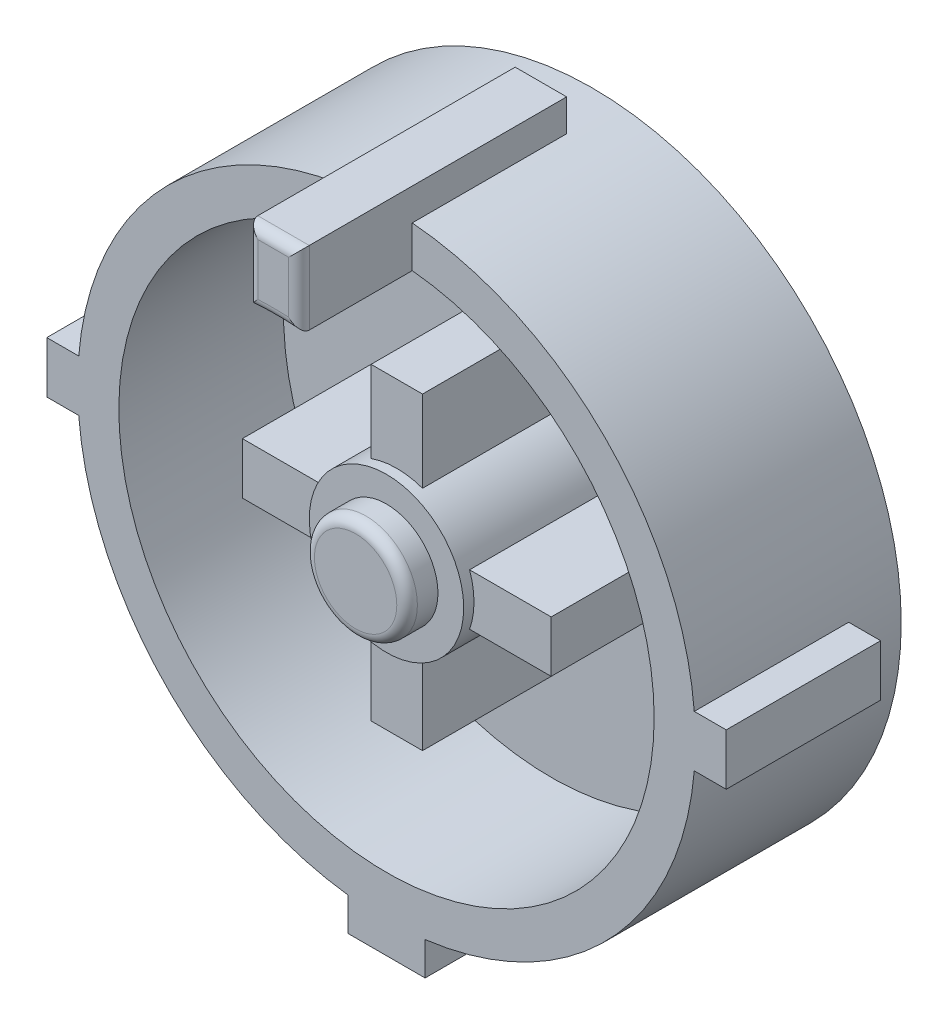
from build123d import *

# Parameters (mm, degrees)
SKETCH_4_R          = 6
EXTRUDE_7_DEPTH     = 4
SKETCH_6_R          = 5.2
CUT_EXTRUDE_3_DEPTH = 3.2
EXTRUDE_8_DEPTH     = 3
EXTRUDE_9_DEPTH     = 2.2
SKETCH_8_R          = 1.5
EXTRUDE_10_DEPTH    = 3.2
EXTRUDE_11_DEPTH    = 3
SKETCH_8_8_R        = 1
EXTRUDE_12_DEPTH    = 3.8
FILLET_1_R          = 0.2


with BuildPart() as part:
    # Sketch 4 → Extrude 7 (new body)
    with BuildSketch(Plane.XY):
        Circle(SKETCH_4_R)
    extrude(amount=EXTRUDE_7_DEPTH)

    # Sketch 6 → Cut-Extrude 3 (cut)
    with BuildSketch(Plane.XY.offset(4)):
        Circle(SKETCH_6_R)
    extrude(amount=-CUT_EXTRUDE_3_DEPTH, mode=Mode.SUBTRACT)

    # Sketch 7 → Extrude 8 (add)
    with BuildSketch(Plane.XY.offset(4)):
        with BuildLine():
            Line((0.5, 6.6), (-0.5, 6.6))
            Line((-0.5, 6.6), (-0.5, 5.979130372))
            ThreePointArc((-0.5, 5.979130372), (0, 6), (0.5, 5.979130372))
            Line((0.5, 5.979130372), (0.5, 6.6))
        make_face()
        with BuildLine():
            ThreePointArc((0.75, -5.95294045), (0, -6), (-0.75, -5.95294045))
            Line((-0.75, -5.95294045), (-0.75, -6.6))
            Line((-0.75, -6.6), (0.75, -6.6))
            Line((0.75, -6.6), (0.75, -5.95294045))
        make_face()
        with BuildLine():
            ThreePointArc((-5.979130372, -0.5), (-6, 0), (-5.979130372, 0.5))
            Line((-5.979130372, 0.5), (-6.6, 0.5))
            Line((-6.6, 0.5), (-6.6, -0.5))
            Line((-6.6, -0.5), (-5.979130372, -0.5))
        make_face()
        with BuildLine():
            Line((6.6, 0.5), (5.979130372, 0.5))
            ThreePointArc((5.979130372, 0.5), (5.994780322, 0.250217676), (6, 0))
            ThreePointArc((6, 0), (5.994780322, -0.250217676), (5.979130372, -0.5))
            Line((5.979130372, -0.5), (6.6, -0.5))
            Line((6.6, -0.5), (6.6, 0.5))
        make_face()
    extrude(amount=-EXTRUDE_8_DEPTH)

    # Sketch 7_3 → Extrude 9 (add)
    with BuildSketch(Plane.XY.offset(4)):
        with BuildLine():
            Line((0.5, 6.6), (-0.5, 6.6))
            Line((-0.5, 6.6), (-0.5, 5.979130372))
            ThreePointArc((-0.5, 5.979130372), (0, 6), (0.5, 5.979130372))
            Line((0.5, 5.979130372), (0.5, 6.6))
        make_face()
        with BuildLine():
            ThreePointArc((0.5, 5.979130372), (0, 6), (-0.5, 5.979130372))
            Line((-0.5, 5.979130372), (-0.5, 5.175905718))
            ThreePointArc((-0.5, 5.175905718), (0, 5.2), (0.5, 5.175905718))
            Line((0.5, 5.175905718), (0.5, 5.979130372))
        make_face()
    extrude(amount=EXTRUDE_9_DEPTH)

    # Sketch 8 → Extrude 10 (add)
    with BuildSketch(Plane.XY.offset(0.8)):
        Circle(SKETCH_8_R)
    extrude(amount=EXTRUDE_10_DEPTH)

    # Sketch 8_3 → Extrude 11 (add)
    with BuildSketch(Plane.XY.offset(0.8)):
        with BuildLine():
            Line((-1.414213562, 0.5), (-3, 0.5))
            Line((-3, 0.5), (-3, -0.5))
            Line((-3, -0.5), (-1.414213562, -0.5))
            ThreePointArc((-1.414213562, -0.5), (-1.5, 0), (-1.414213562, 0.5))
        make_face()
        with BuildLine():
            Line((-0.5, 3), (-0.5, 1.414213562))
            ThreePointArc((-0.5, 1.414213562), (0, 1.5), (0.5, 1.414213562))
            Line((0.5, 1.414213562), (0.5, 3))
            Line((0.5, 3), (-0.5, 3))
        make_face()
        with BuildLine():
            Line((3, 0.5), (1.414213562, 0.5))
            ThreePointArc((1.414213562, 0.5), (1.478397839, 0.253652968), (1.5, 0))
            ThreePointArc((1.5, 0), (1.478397839, -0.253652968), (1.414213562, -0.5))
            Line((1.414213562, -0.5), (3, -0.5))
            Line((3, -0.5), (3, 0.5))
        make_face()
        with BuildLine():
            ThreePointArc((0.5, -1.414213562), (0, -1.5), (-0.5, -1.414213562))
            Line((-0.5, -1.414213562), (-0.5, -3))
            Line((-0.5, -3), (0.5, -3))
            Line((0.5, -3), (0.5, -1.414213562))
        make_face()
    extrude(amount=EXTRUDE_11_DEPTH)

    # Sketch 8_8 → Extrude 12 (add)
    with BuildSketch(Plane.XY.offset(0.8)):
        Circle(SKETCH_8_8_R)
    extrude(amount=EXTRUDE_12_DEPTH)

    # Fillet 1
    fillet_1_edges = [part.edges().sort_by_distance(p)[0] for p in [
        (-1, 0, 4.6),
        (0.5, 5.887952859, 6.2),
        (0, 6.6, 6.2),
        (-0.5, 5.887952859, 6.2),
        (0, 5.2, 6.2),
    ]]
    fillet(fillet_1_edges, radius=FILLET_1_R)


solid = part.part
